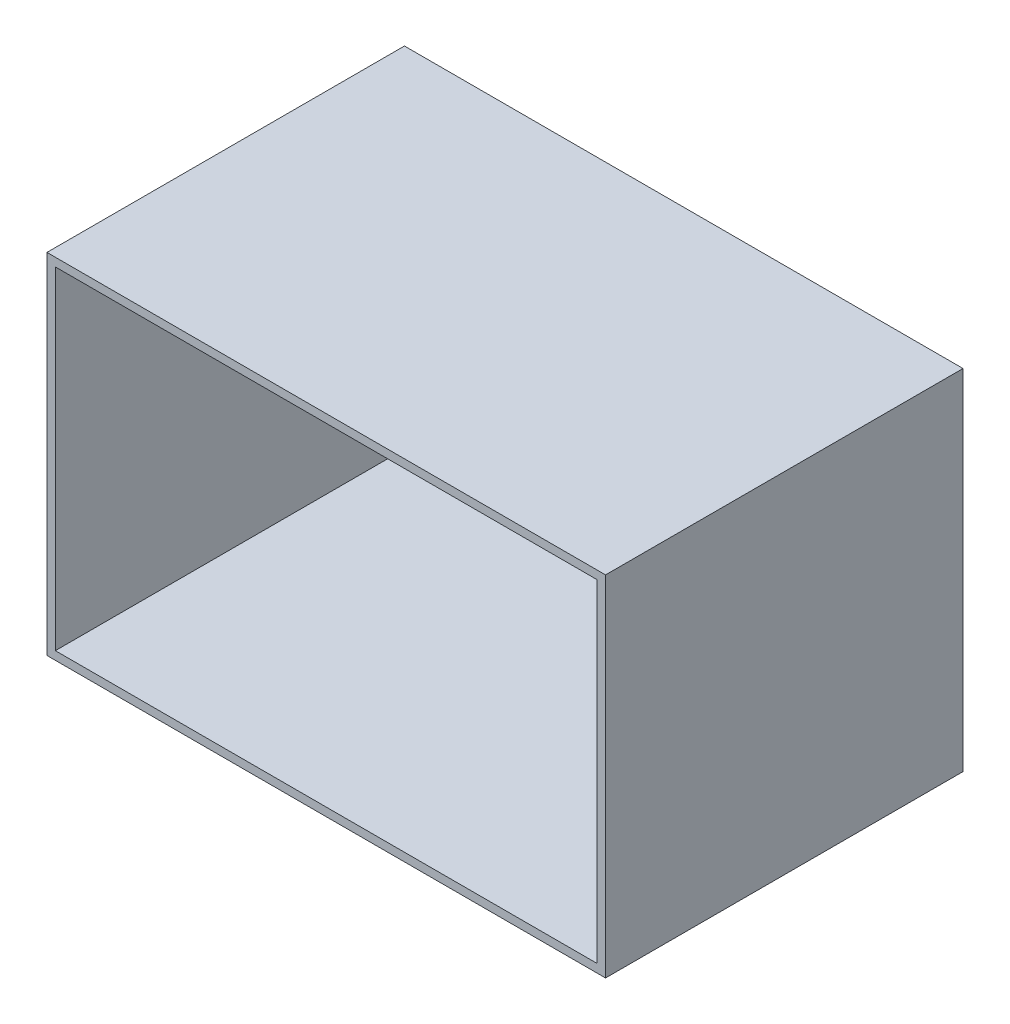
from build123d import *

# Parameters (mm, degrees)
CROQUIS1_W              = 400
CROQUIS1_H              = 250
SALIENTE_EXTRUIR2_DEPTH = 6
CROQUIS2_W              = 400
CROQUIS2_H              = 250
CROQUIS2_W_2            = 388
CROQUIS2_H_2            = 238
SALIENTE_EXTRUIR3_DEPTH = 250


with BuildPart() as part:
    # Croquis1 → Saliente-Extruir2 (new body)
    with BuildSketch(Plane.XY):
        Rectangle(CROQUIS1_W, CROQUIS1_H)
    extrude(amount=SALIENTE_EXTRUIR2_DEPTH)

    # Croquis2 → Saliente-Extruir3 (add)
    with BuildSketch(Plane.XY.offset(6)):
        Rectangle(CROQUIS2_W, CROQUIS2_H)
        Rectangle(CROQUIS2_W_2, CROQUIS2_H_2, mode=Mode.SUBTRACT)
    extrude(amount=SALIENTE_EXTRUIR3_DEPTH)


solid = part.part
